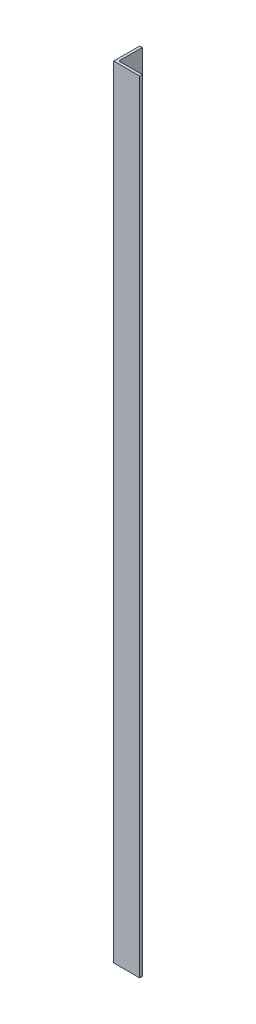
from build123d import *

# Parameters (mm, degrees)
EXTRUDE_1_DEPTH = 1500


with BuildPart() as part:
    # Эскиз1 → Вытянуть-Тонкостенный1 (new body)
    with BuildSketch(Plane(origin=(0, 0, 0), x_dir=(1, 0, 0), z_dir=(0, 1, 0))):
        Polygon((50, 0), (0, 0), (0, 50), (5, 50), (5, 5), (50, 5), align=None)
    extrude(amount=EXTRUDE_1_DEPTH)


solid = part.part
